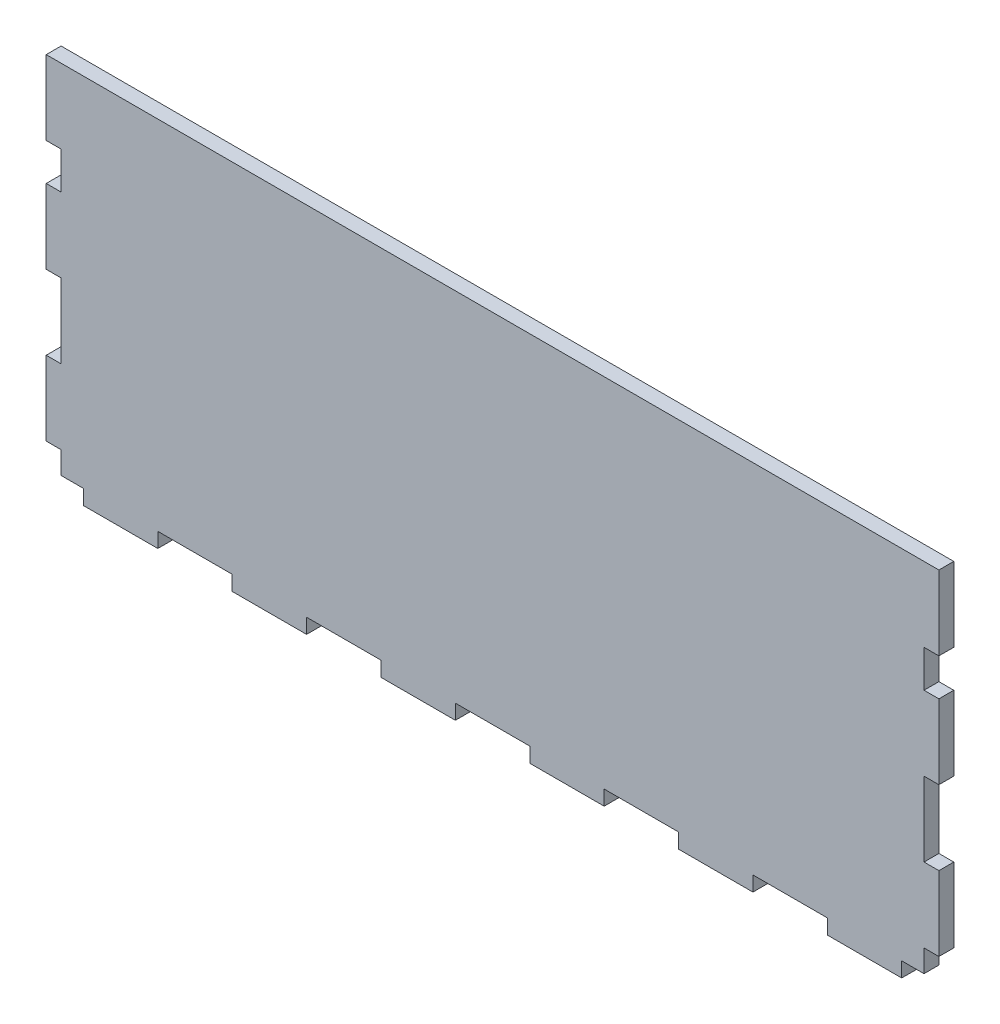
from build123d import *

# Parameters (mm, degrees)
BOSS_EXTRUDE1_DEPTH = 2.54


with BuildPart() as part:
    # Sketch1 → Boss-Extrude1 (new body, symmetric)
    with BuildSketch(Plane.XY):
        Polygon((152.4, -25.4), (152.4, 0), (-152.4, 0), (-152.4, -25.4), (-147.32, -25.4), (-147.32, -38.1), (-152.4, -38.1), (-152.4, -63.5), (-147.32, -63.5), (-147.32, -88.9), (-152.4, -88.9), (-152.4, -114.3), (-147.32, -114.3), (-147.32, -121.92), (-139.7, -121.92), (-139.7, -127), (-114.3, -127), (-114.3, -121.92), (-88.9, -121.92), (-88.9, -127), (-63.5, -127), (-63.5, -121.92), (-38.1, -121.92), (-38.1, -127), (-12.7, -127), (-12.7, -121.92), (12.7, -121.92), (12.7, -127), (38.1, -127), (38.1, -121.92), (63.5, -121.92), (63.5, -127), (88.9, -127), (88.9, -121.92), (114.3, -121.92), (114.3, -127), (139.7, -127), (139.7, -121.92), (147.32, -121.92), (147.32, -114.3), (152.4, -114.3), (152.4, -88.9), (147.32, -88.9), (147.32, -63.5), (152.4, -63.5), (152.4, -38.1), (147.32, -38.1), (147.32, -25.4), align=None)
    extrude(amount=BOSS_EXTRUDE1_DEPTH, both=True)


solid = part.part
